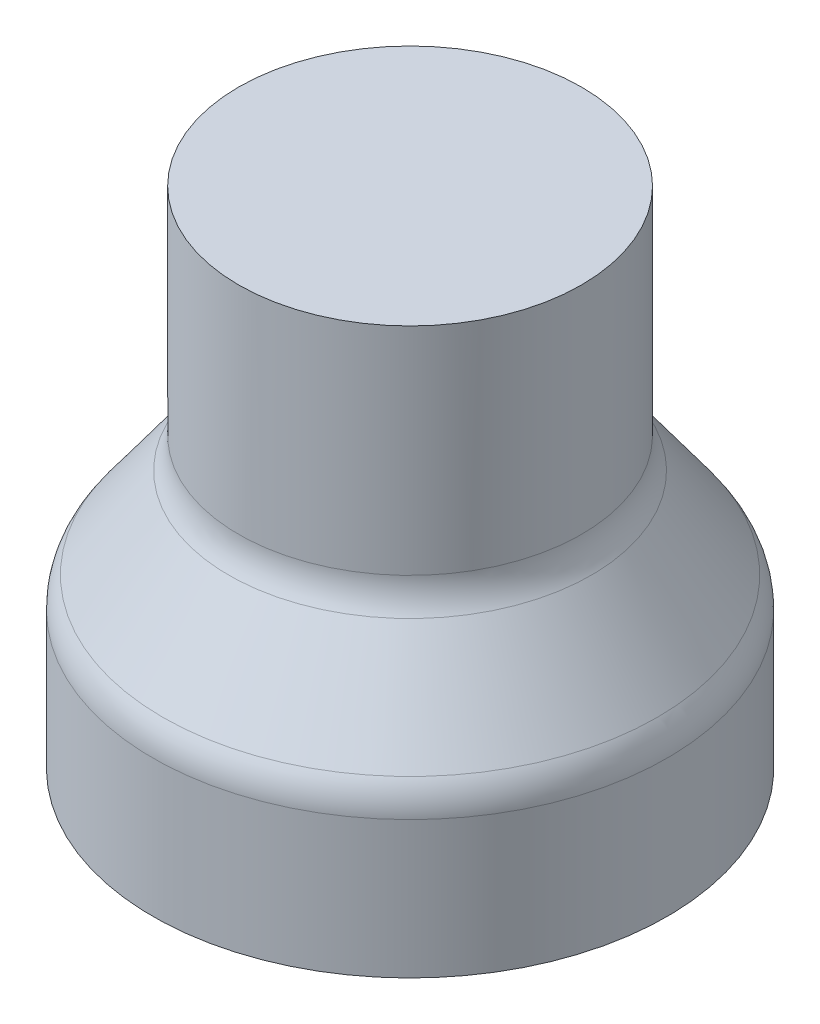
from build123d import *

# Parameters (mm, degrees)
SKETCH8_R           = 2.5
BOSS_EXTRUDE1_DEPTH = 1.15


with BuildPart() as part:
    # Sketch6 → Revolve-Thin2 (revolve)
    with BuildSketch(Plane(origin=(0, 0, 0), x_dir=(0, 0, -1), z_dir=(1, 0, 0))):
        with BuildLine():
            Line((-3.75, 0), (-3.75, 2))
            ThreePointArc((-3.75, 2), (-3.712963507, 2.232772503), (-3.605511899, 2.442555466))
            Line((-3.605511899, 2.442555466), (-2.644488101, 3.757444534))
            ThreePointArc((-2.644488101, 3.757444534), (-2.537036493, 3.967227497), (-2.5, 4.2))
            Line((-2.5, 4.2), (-2.5, 6.2))
            Line((-2.5, 6.2), (-2, 6.2))
            Line((-2, 6.2), (-2, 4.2))
            ThreePointArc((-2, 4.2), (-2.061727489, 3.812045829), (-2.240813502, 3.462407557))
            Line((-2.240813502, 3.462407557), (-3.2018373, 2.147518489))
            ThreePointArc((-3.2018373, 2.147518489), (-3.237654502, 2.077590834), (-3.25, 2))
            Line((-3.25, 2), (-3.25, 0))
            Line((-3.25, 0), (-3.75, 0))
        make_face()
    revolve(axis=Axis((0, -0.227579974, 0), (0, 1, 0)))

    # Sketch8 → Boss-Extrude1 (add)
    with BuildSketch(Plane(origin=(0, 6.2, 0), x_dir=(1, 0, 0), z_dir=(0, 1, 0))):
        Circle(SKETCH8_R)
    extrude(amount=BOSS_EXTRUDE1_DEPTH)


solid = part.part
